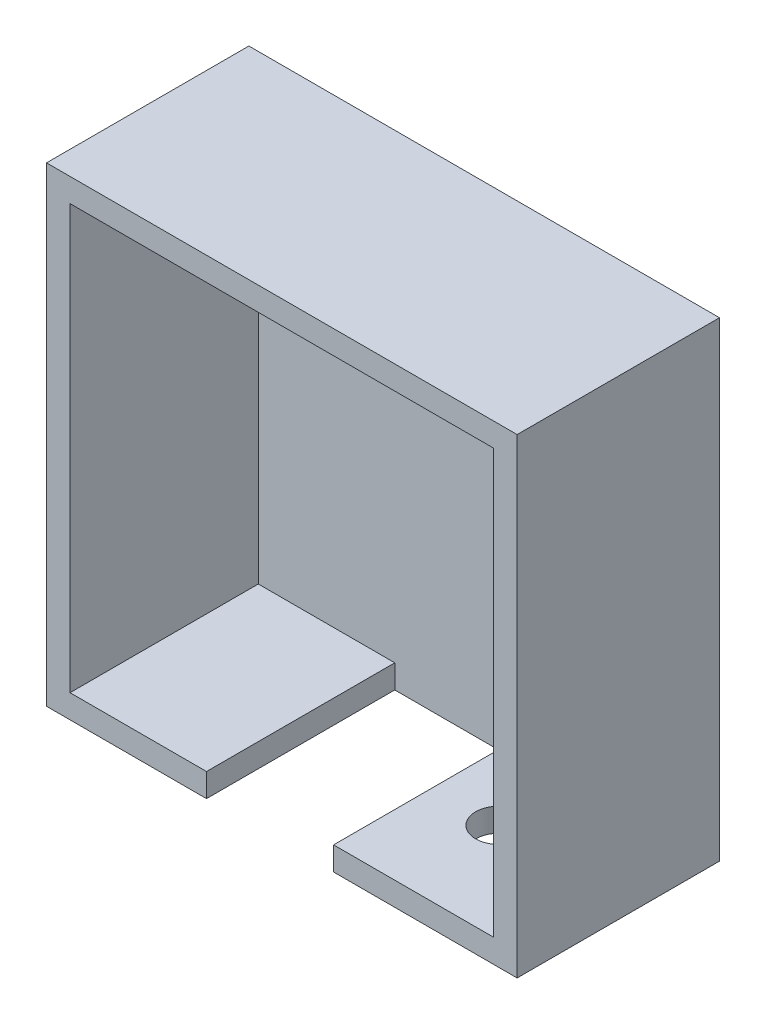
from build123d import *

# Parameters (mm, degrees)
SKETCH1_W           = 100
SKETCH1_H           = 100
BOSS_EXTRUDE1_DEPTH = 3
BOSS_EXTRUDE2_DEPTH = 40
SKETCH3_R           = 5
CUT_EXTRUDE1_DEPTH  = 40


with BuildPart() as part:
    # Sketch1 → Boss-Extrude1 (new body)
    with BuildSketch(Plane.XY):
        with Locations((50, -50)):
            Rectangle(SKETCH1_W, SKETCH1_H)
    extrude(amount=BOSS_EXTRUDE1_DEPTH)

    # Sketch2 → Boss-Extrude2 (add)
    with BuildSketch(Plane.XY.offset(3)):
        Polygon((0, 0), (100, 0), (100, -5), (100, -100), (61, -100), (61, -95), (95, -95), (95, -5), (5, -5), (5, -95), (34, -95), (34, -100), (0, -100), (0, -6.075944417), align=None)
    extrude(amount=BOSS_EXTRUDE2_DEPTH)

    # Sketch3 → Cut-Extrude1 (cut)
    with BuildSketch(Plane.XZ.offset(100)):
        with Locations((75, 21.806521963)):
            Circle(SKETCH3_R)
    extrude(amount=-CUT_EXTRUDE1_DEPTH, mode=Mode.SUBTRACT)


solid = part.part
